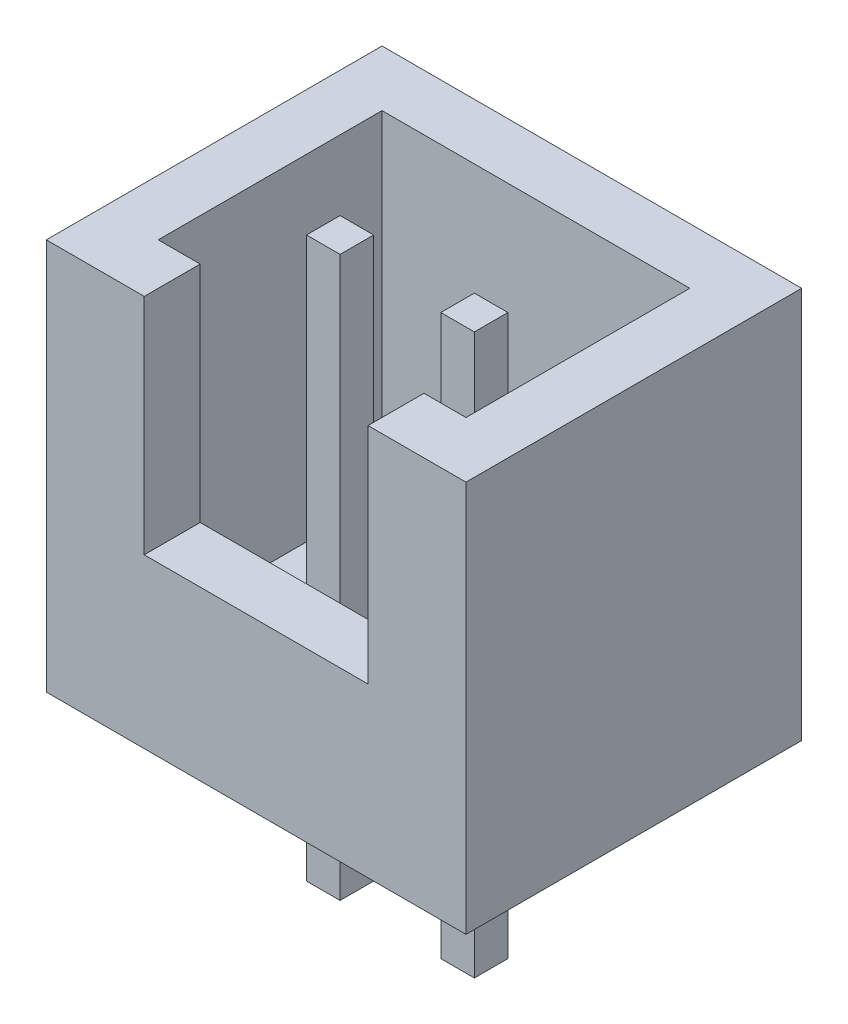
from build123d import *

# Parameters (mm, degrees)
SKETCH_1_W          = 7.5
SKETCH_1_H          = 6
EXTRUDE_1_DEPTH     = 7
SHELL_1_T           = -1
CUT_EXTRUDE_1_REACH = 8
SKETCH_2_W          = 4
SKETCH_2_H          = 4
EXTRUDE_START       = -7
SKETCH_3_W          = 0.6
SKETCH_3_H          = 0.6
EXTRUDE_2_DEPTH     = 10


with BuildPart() as part:
    # 草图1 → 凸台-拉伸1 (new body)
    with BuildSketch(Plane(origin=(0, 0, 0), x_dir=(1, 0, 0), z_dir=(0, 1, 0))):
        Rectangle(SKETCH_1_W, SKETCH_1_H)
    extrude(amount=EXTRUDE_1_DEPTH)

    # 抽壳1
    shell_1_openings = [part.faces().sort_by_distance(p)[0] for p in [
        (0, 7, 0),
    ]]
    offset(amount=SHELL_1_T, openings=shell_1_openings, kind=Kind.INTERSECTION)

    # 草图2 → 切除-拉伸1 (cut, up to next)
    with BuildSketch(Plane.XY.offset(3), mode=Mode.PRIVATE) as cut_extrude_1_sk1:
        with Locations((0, 5)):
            Rectangle(SKETCH_2_W, SKETCH_2_H)
    cut_extrude_1_tool1 = extrude(cut_extrude_1_sk1.sketch, amount=-CUT_EXTRUDE_1_REACH, mode=Mode.PRIVATE) & part.part
    add(cut_extrude_1_tool1.solids().sort_by_distance((0, 5, 3))[0], mode=Mode.SUBTRACT)

    # 草图3 → 凸台-拉伸2 (add)
    with BuildSketch(Plane.XZ.offset(EXTRUDE_START)):
        with Locations((-1.2, 0.3)):
            Rectangle(SKETCH_3_W, SKETCH_3_H)
        with Locations((1.2, 0.3)):
            Rectangle(SKETCH_3_W, SKETCH_3_H)
    extrude(amount=EXTRUDE_2_DEPTH)


solid = part.part
